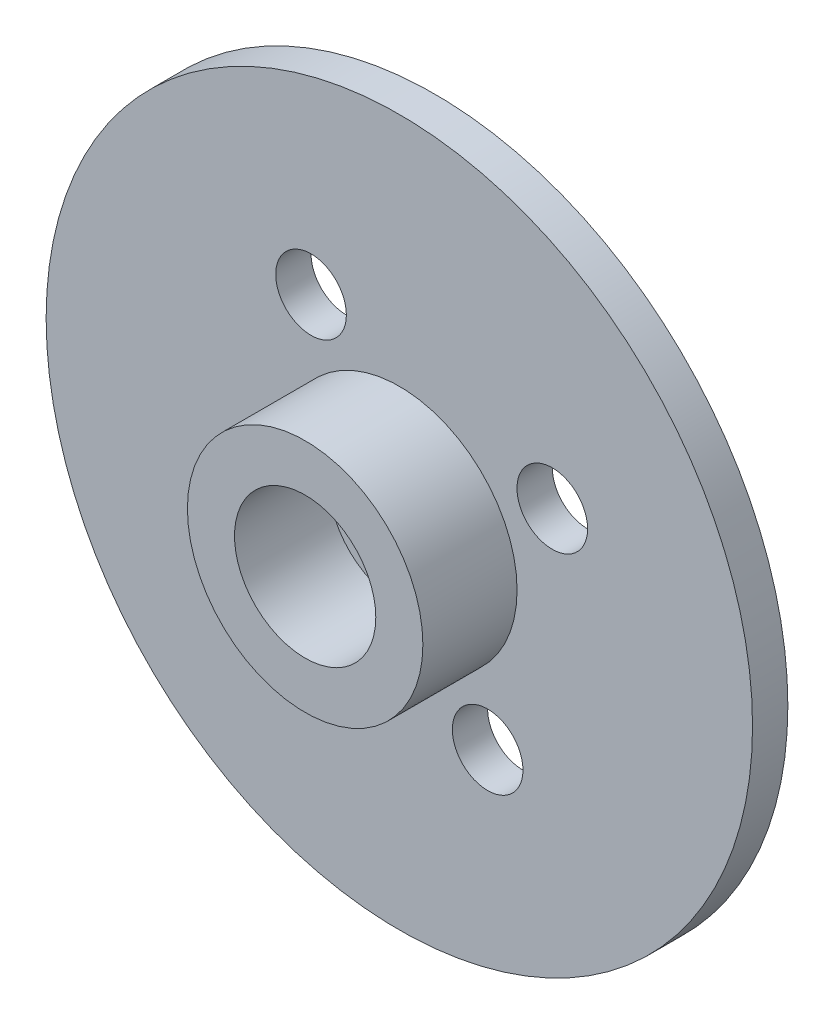
from build123d import *

# Parameters (mm, degrees)
SKETCH1_R           = 15
SKETCH1_R_2         = 1.5
SKETCH1_R_3         = 1
BOSS_EXTRUDE1_DEPTH = 1.5
SKETCH2_R           = 5
SKETCH2_R_2         = 3
BOSS_EXTRUDE2_DEPTH = 4


with BuildPart() as part:
    # Sketch1 → Boss-Extrude1 (new body)
    with BuildSketch(Plane.XY):
        with Locations((-39.444879197, 67.794412983)):
            Circle(SKETCH1_R)
        with Locations((-32.949688669, 71.544412983)):
            Circle(SKETCH1_R_2, mode=Mode.SUBTRACT)
        with Locations((-45.940069726, 64.044412983)):
            Circle(SKETCH1_R_2, mode=Mode.SUBTRACT)
        with Locations((-39.444879197, 67.794412983)):
            Circle(SKETCH1_R_3, mode=Mode.SUBTRACT)
        with Locations((-35.694879197, 61.299222454)):
            Circle(SKETCH1_R_2, mode=Mode.SUBTRACT)
        with Locations((-43.194879197, 74.289603511)):
            Circle(SKETCH1_R_2, mode=Mode.SUBTRACT)
    extrude(amount=BOSS_EXTRUDE1_DEPTH)

    # Sketch2 → Boss-Extrude2 (add)
    with BuildSketch(Plane.XY.offset(1.5)):
        with Locations((-39.444879197, 67.794412983)):
            Circle(SKETCH2_R)
        with Locations((-39.444879197, 67.794412983)):
            Circle(SKETCH2_R_2, mode=Mode.SUBTRACT)
    extrude(amount=BOSS_EXTRUDE2_DEPTH)


solid = part.part
